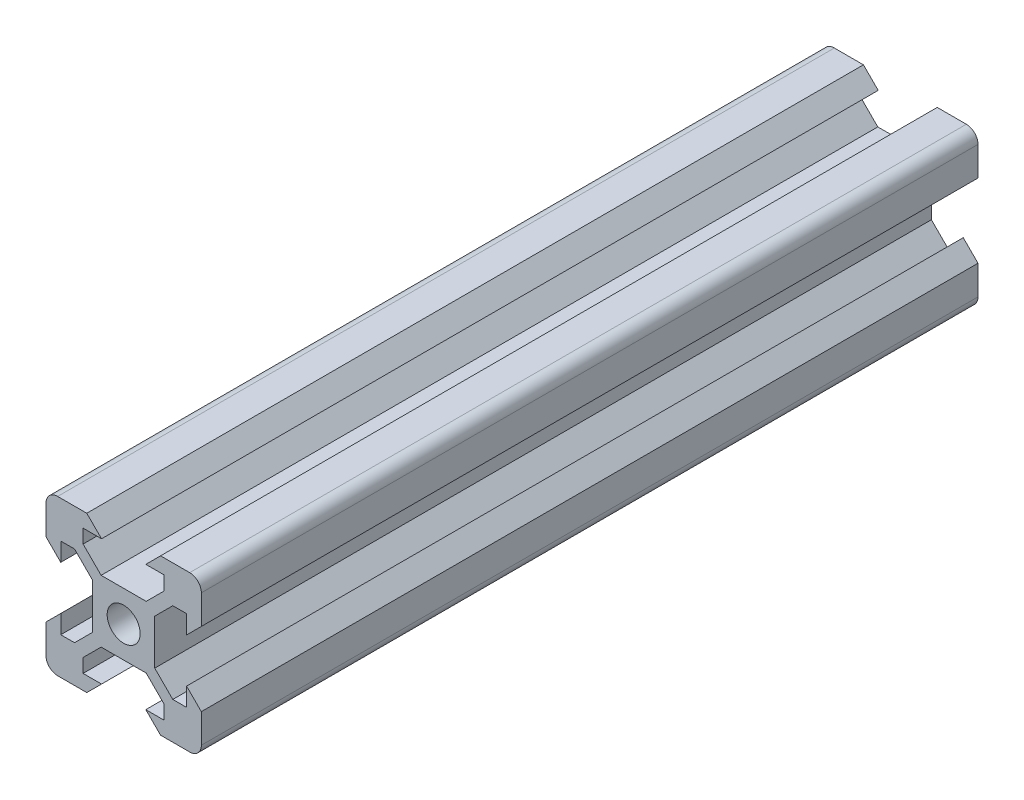
from build123d import *

# Parameters (mm, degrees)
SKETCH1_R           = 2.125
BOSS_EXTRUDE1_DEPTH = 100


with BuildPart() as part:
    # Sketch1 → Boss-Extrude1 (new body)
    with BuildSketch(Plane.XY):
        with BuildLine():
            Line((8.1, 5.225), (8.1, 2.85))
            Line((8.1, 2.85), (10, 4.75))
            Line((10, 4.75), (10, 8.5))
            ThreePointArc((10, 8.5), (9.560660172, 9.560660172), (8.5, 10))
            Line((8.5, 10), (4.75, 10))
            Line((4.75, 10), (2.85, 8.1))
            Line((2.85, 8.1), (5.225, 8.1))
            Line((5.225, 8.1), (5.225, 6.325))
            Line((5.225, 6.325), (2.9, 4))
            Line((2.9, 4), (-2.9, 4))
            Line((-2.9, 4), (-5.225, 6.325))
            Line((-5.225, 6.325), (-5.225, 8.1))
            Line((-5.225, 8.1), (-2.85, 8.1))
            Line((-2.85, 8.1), (-4.75, 10))
            Line((-4.75, 10), (-8.5, 10))
            ThreePointArc((-8.5, 10), (-9.560660172, 9.560660172), (-10, 8.5))
            Line((-10, 8.5), (-10, 4.75))
            Line((-10, 4.75), (-8.1, 2.85))
            Line((-8.1, 2.85), (-8.1, 5.225))
            Line((-8.1, 5.225), (-6.325, 5.225))
            Line((-6.325, 5.225), (-4, 2.9))
            Line((-4, 2.9), (-4, -2.9))
            Line((-4, -2.9), (-6.325, -5.225))
            Line((-6.325, -5.225), (-8.1, -5.225))
            Line((-8.1, -5.225), (-8.1, -2.85))
            Line((-8.1, -2.85), (-10, -4.75))
            Line((-10, -4.75), (-10, -8.5))
            ThreePointArc((-10, -8.5), (-9.560660172, -9.560660172), (-8.5, -10))
            Line((-8.5, -10), (-4.75, -10))
            Line((-4.75, -10), (-2.85, -8.1))
            Line((-2.85, -8.1), (-5.225, -8.1))
            Line((-5.225, -8.1), (-5.225, -6.325))
            Line((-5.225, -6.325), (-2.9, -4))
            Line((-2.9, -4), (2.9, -4))
            Line((2.9, -4), (5.225, -6.325))
            Line((5.225, -6.325), (5.225, -8.1))
            Line((5.225, -8.1), (2.85, -8.1))
            Line((2.85, -8.1), (4.75, -10))
            Line((4.75, -10), (8.5, -10))
            ThreePointArc((8.5, -10), (9.560660172, -9.560660172), (10, -8.5))
            Line((10, -8.5), (10, -4.75))
            Line((10, -4.75), (8.1, -2.85))
            Line((8.1, -2.85), (8.1, -5.225))
            Line((8.1, -5.225), (6.325, -5.225))
            Line((6.325, -5.225), (4, -2.9))
            Line((4, -2.9), (4, 2.9))
            Line((4, 2.9), (6.325, 5.225))
            Line((6.325, 5.225), (8.1, 5.225))
        make_face()
        Circle(SKETCH1_R, mode=Mode.SUBTRACT)
    extrude(amount=BOSS_EXTRUDE1_DEPTH)


solid = part.part
